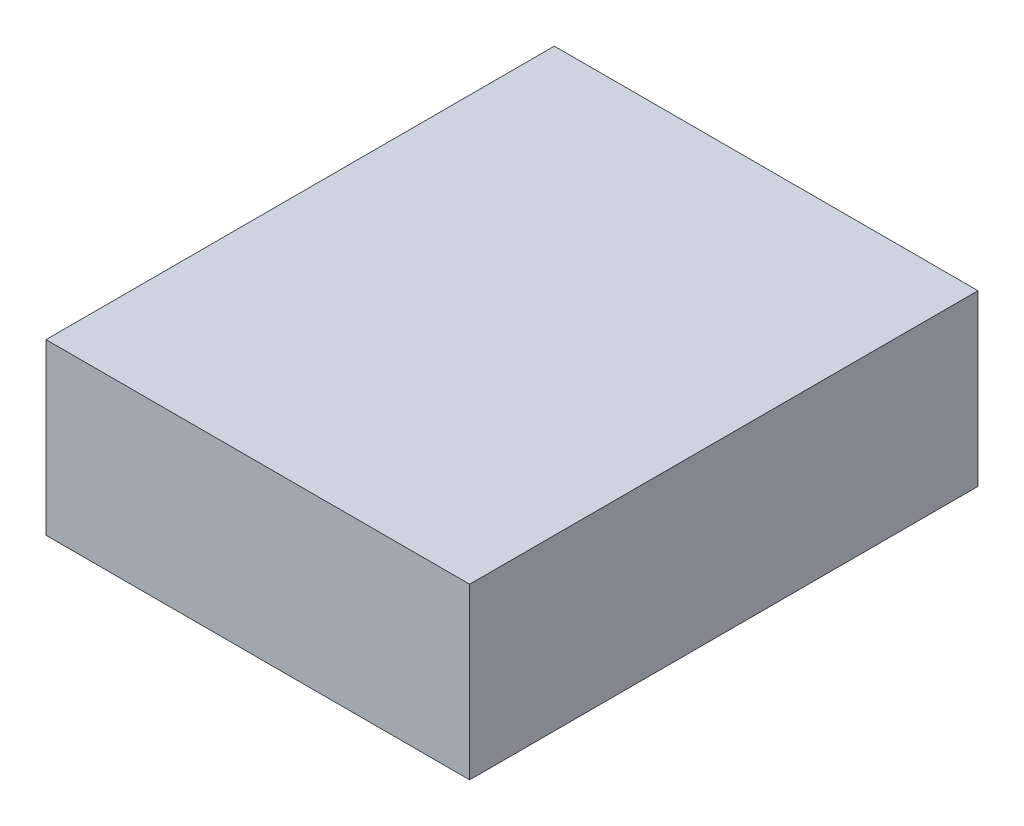
from build123d import *

# Parameters (mm, degrees)
SKETCH1_W           = 2.5
SKETCH1_H           = 3
BOSS_EXTRUDE1_DEPTH = 1


with BuildPart() as part:
    # Sketch1 → Boss-Extrude1 (new body)
    with BuildSketch(Plane(origin=(0, 0, 0), x_dir=(1, 0, 0), z_dir=(0, 1, 0))):
        with Locations((1.25, 1.5)):
            Rectangle(SKETCH1_W, SKETCH1_H)
    extrude(amount=BOSS_EXTRUDE1_DEPTH)


solid = part.part
